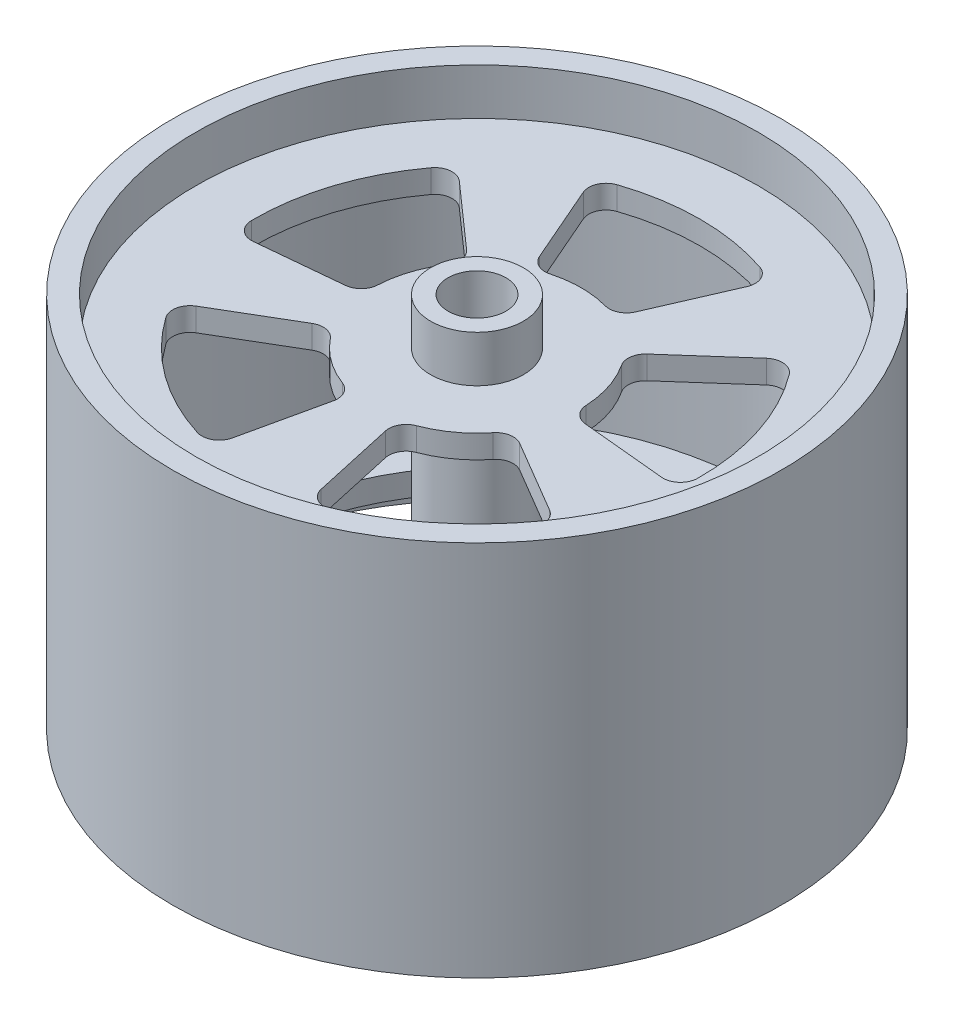
from build123d import *

# Parameters (mm, degrees)
SKETCH1_R           = 52.5
SKETCH1_R_2         = 48.5
BOSS_EXTRUDE1_DEPTH = 65
SKETCH2_R           = 5
BOSS_EXTRUDE2_DEPTH = 65
BOSS_EXTRUDE3_START = -8
SKETCH2_3_R         = 48.5
SKETCH2_3_R_2       = 8
BOSS_EXTRUDE3_DEPTH = 4
BOSS_EXTRUDE4_START = -53
SKETCH2_4_R         = 48.5
SKETCH2_4_R_2       = 8
BOSS_EXTRUDE4_DEPTH = 4


with BuildPart() as part:
    # Sketch1 → Boss-Extrude1 (new body)
    with BuildSketch(Plane(origin=(0, 0, 0), x_dir=(1, 0, 0), z_dir=(0, 1, 0))):
        Circle(SKETCH1_R)
        Circle(SKETCH1_R_2, mode=Mode.SUBTRACT)
    extrude(amount=BOSS_EXTRUDE1_DEPTH)



with BuildPart() as body_2:
    # Sketch2 → Boss-Extrude2 (new body)
    with BuildSketch(Plane.XZ):
        with BuildLine():
            ThreePointArc((8, 0), (7.901506725, 1.25147572), (7.60845213, 2.472135955))
            ThreePointArc((7.60845213, 2.472135955), (4.702282018, 6.472135955), (0, 8))
            ThreePointArc((0, 8), (-5.656854249, -5.656854249), (8, 0))
        make_face()
        Circle(SKETCH2_R, mode=Mode.SUBTRACT)
    extrude(amount=-BOSS_EXTRUDE2_DEPTH)


with BuildPart() as part_1:
    add(part.part)

    add(body_2.part)  # Boss-Extrude3 merges body 2
    # Sketch2_3 → Boss-Extrude3 (add)
    with BuildSketch(Plane.XZ.offset(BOSS_EXTRUDE3_START)):
        Circle(SKETCH2_3_R)
        Circle(SKETCH2_3_R_2, mode=Mode.SUBTRACT)
        with BuildLine():
            Line((4.498612897, 20.291931451), (7.656121129, 34.53453068))
            ThreePointArc((7.656121129, 34.53453068), (9.081556968, 36.48129187), (11.479516965, 36.748750866))
            ThreePointArc((11.479516965, 36.748750866), (22.629732213, 31.147154283), (31.402773148, 22.273657954))
            ThreePointArc((31.402773148, 22.273657954), (31.889414918, 19.910413097), (30.4784189, 17.953160762))
            Line((30.4784189, 17.953160762), (17.908625798, 10.548986777))
            ThreePointArc((17.908625798, 10.548986777), (15.84479345, 10.183097432), (14.045152036, 11.257606507))
            ThreePointArc((14.045152036, 11.257606507), (10.580134541, 14.562305899), (6.366429359, 16.836525093))
            ThreePointArc((6.366429359, 16.836525093), (4.78839072, 18.216044222), (4.498612897, 20.291931451))
        make_face(mode=Mode.SUBTRACT)
        with BuildLine():
            ThreePointArc((-31.402773148, 22.273657954), (-22.629732213, 31.147154283), (-11.479516965, 36.748750866))
            ThreePointArc((-11.479516965, 36.748750866), (-9.081556968, 36.48129187), (-7.656121129, 34.53453068))
            Line((-7.656121129, 34.53453068), (-4.498612897, 20.291931451))
            ThreePointArc((-4.498612897, 20.291931451), (-4.78839072, 18.216044222), (-6.366429359, 16.836525093))
            ThreePointArc((-6.366429359, 16.836525093), (-10.580134541, 14.562305899), (-14.045152036, 11.257606507))
            ThreePointArc((-14.045152036, 11.257606507), (-15.84479345, 10.183097432), (-17.908625798, 10.548986777))
            Line((-17.908625798, 10.548986777), (-30.4784189, 17.953160762))
            ThreePointArc((-30.4784189, 17.953160762), (-31.889414918, 19.910413097), (-31.402773148, 22.273657954))
        make_face(mode=Mode.SUBTRACT)
        with BuildLine():
            Line((8.287843762, -19.060735709), (14.104955724, -32.439177302))
            ThreePointArc((14.104955724, -32.439177302), (14.096031424, -34.851990353), (12.313249487, -36.477854749))
            ThreePointArc((12.313249487, -36.477854749), (0, -38.5), (-12.313249487, -36.477854749))
            ThreePointArc((-12.313249487, -36.477854749), (-14.096031424, -34.851990353), (-14.104955724, -32.439177302))
            Line((-14.104955724, -32.439177302), (-8.287843762, -19.060735709))
            ThreePointArc((-8.287843762, -19.060735709), (-6.83323268, -17.551634794), (-4.745711605, -17.363128214))
            ThreePointArc((-4.745711605, -17.363128214), (0, -18), (4.745711605, -17.363128214))
            ThreePointArc((4.745711605, -17.363128214), (6.83323268, -17.551634794), (8.287843762, -19.060735709))
        make_face(mode=Mode.SUBTRACT)
        with BuildLine():
            Line((-15.566752332, -13.772299075), (-26.492819932, -23.438867123))
            ThreePointArc((-26.492819932, -23.438867123), (-28.790299268, -24.175979847), (-30.887498112, -22.982873197))
            ThreePointArc((-30.887498112, -22.982873197), (-36.615675877, -11.897154283), (-38.497504807, 0.438319126))
            ThreePointArc((-38.497504807, 0.438319126), (-37.502125795, 2.636265233), (-35.21016198, 3.390352984))
            Line((-35.21016198, 3.390352984), (-20.688921471, 1.992116557))
            ThreePointArc((-20.688921471, 1.992116557), (-18.804181667, 1.075037038), (-17.979821767, -0.852061747))
            ThreePointArc((-17.979821767, -0.852061747), (-17.119017293, -5.562305899), (-15.046810695, -9.87894164))
            ThreePointArc((-15.046810695, -9.87894164), (-14.581011618, -11.922543898), (-15.566752332, -13.772299075))
        make_face(mode=Mode.SUBTRACT)
        with BuildLine():
            Line((20.688921471, 1.992116557), (35.21016198, 3.390352984))
            ThreePointArc((35.21016198, 3.390352984), (37.502125795, 2.636265233), (38.497504807, 0.438319126))
            ThreePointArc((38.497504807, 0.438319126), (36.615675877, -11.897154283), (30.887498112, -22.982873197))
            ThreePointArc((30.887498112, -22.982873197), (28.790299268, -24.175979847), (26.492819932, -23.438867123))
            Line((26.492819932, -23.438867123), (15.566752332, -13.772299075))
            ThreePointArc((15.566752332, -13.772299075), (14.581011618, -11.922543898), (15.046810695, -9.87894164))
            ThreePointArc((15.046810695, -9.87894164), (17.119017293, -5.562305899), (17.979821767, -0.852061747))
            ThreePointArc((17.979821767, -0.852061747), (18.804181667, 1.075037038), (20.688921471, 1.992116557))
        make_face(mode=Mode.SUBTRACT)
    extrude(amount=-BOSS_EXTRUDE3_DEPTH)

    # Sketch2_4 → Boss-Extrude4 (add)
    with BuildSketch(Plane.XZ.offset(BOSS_EXTRUDE4_START)):
        Circle(SKETCH2_4_R)
        Circle(SKETCH2_4_R_2, mode=Mode.SUBTRACT)
        with BuildLine():
            Line((4.498612897, 20.291931451), (7.656121129, 34.53453068))
            ThreePointArc((7.656121129, 34.53453068), (9.081556968, 36.48129187), (11.479516965, 36.748750866))
            ThreePointArc((11.479516965, 36.748750866), (22.629732213, 31.147154283), (31.402773148, 22.273657954))
            ThreePointArc((31.402773148, 22.273657954), (31.889414918, 19.910413097), (30.4784189, 17.953160762))
            Line((30.4784189, 17.953160762), (17.908625798, 10.548986777))
            ThreePointArc((17.908625798, 10.548986777), (15.84479345, 10.183097432), (14.045152036, 11.257606507))
            ThreePointArc((14.045152036, 11.257606507), (10.580134541, 14.562305899), (6.366429359, 16.836525093))
            ThreePointArc((6.366429359, 16.836525093), (4.78839072, 18.216044222), (4.498612897, 20.291931451))
        make_face(mode=Mode.SUBTRACT)
        with BuildLine():
            ThreePointArc((-31.402773148, 22.273657954), (-22.629732213, 31.147154283), (-11.479516965, 36.748750866))
            ThreePointArc((-11.479516965, 36.748750866), (-9.081556968, 36.48129187), (-7.656121129, 34.53453068))
            Line((-7.656121129, 34.53453068), (-4.498612897, 20.291931451))
            ThreePointArc((-4.498612897, 20.291931451), (-4.78839072, 18.216044222), (-6.366429359, 16.836525093))
            ThreePointArc((-6.366429359, 16.836525093), (-10.580134541, 14.562305899), (-14.045152036, 11.257606507))
            ThreePointArc((-14.045152036, 11.257606507), (-15.84479345, 10.183097432), (-17.908625798, 10.548986777))
            Line((-17.908625798, 10.548986777), (-30.4784189, 17.953160762))
            ThreePointArc((-30.4784189, 17.953160762), (-31.889414918, 19.910413097), (-31.402773148, 22.273657954))
        make_face(mode=Mode.SUBTRACT)
        with BuildLine():
            Line((8.287843762, -19.060735709), (14.104955724, -32.439177302))
            ThreePointArc((14.104955724, -32.439177302), (14.096031424, -34.851990353), (12.313249487, -36.477854749))
            ThreePointArc((12.313249487, -36.477854749), (0, -38.5), (-12.313249487, -36.477854749))
            ThreePointArc((-12.313249487, -36.477854749), (-14.096031424, -34.851990353), (-14.104955724, -32.439177302))
            Line((-14.104955724, -32.439177302), (-8.287843762, -19.060735709))
            ThreePointArc((-8.287843762, -19.060735709), (-6.83323268, -17.551634794), (-4.745711605, -17.363128214))
            ThreePointArc((-4.745711605, -17.363128214), (0, -18), (4.745711605, -17.363128214))
            ThreePointArc((4.745711605, -17.363128214), (6.83323268, -17.551634794), (8.287843762, -19.060735709))
        make_face(mode=Mode.SUBTRACT)
        with BuildLine():
            Line((-15.566752332, -13.772299075), (-26.492819932, -23.438867123))
            ThreePointArc((-26.492819932, -23.438867123), (-28.790299268, -24.175979847), (-30.887498112, -22.982873197))
            ThreePointArc((-30.887498112, -22.982873197), (-36.615675877, -11.897154283), (-38.497504807, 0.438319126))
            ThreePointArc((-38.497504807, 0.438319126), (-37.502125795, 2.636265233), (-35.21016198, 3.390352984))
            Line((-35.21016198, 3.390352984), (-20.688921471, 1.992116557))
            ThreePointArc((-20.688921471, 1.992116557), (-18.804181667, 1.075037038), (-17.979821767, -0.852061747))
            ThreePointArc((-17.979821767, -0.852061747), (-17.119017293, -5.562305899), (-15.046810695, -9.87894164))
            ThreePointArc((-15.046810695, -9.87894164), (-14.581011618, -11.922543898), (-15.566752332, -13.772299075))
        make_face(mode=Mode.SUBTRACT)
        with BuildLine():
            Line((20.688921471, 1.992116557), (35.21016198, 3.390352984))
            ThreePointArc((35.21016198, 3.390352984), (37.502125795, 2.636265233), (38.497504807, 0.438319126))
            ThreePointArc((38.497504807, 0.438319126), (36.615675877, -11.897154283), (30.887498112, -22.982873197))
            ThreePointArc((30.887498112, -22.982873197), (28.790299268, -24.175979847), (26.492819932, -23.438867123))
            Line((26.492819932, -23.438867123), (15.566752332, -13.772299075))
            ThreePointArc((15.566752332, -13.772299075), (14.581011618, -11.922543898), (15.046810695, -9.87894164))
            ThreePointArc((15.046810695, -9.87894164), (17.119017293, -5.562305899), (17.979821767, -0.852061747))
            ThreePointArc((17.979821767, -0.852061747), (18.804181667, 1.075037038), (20.688921471, 1.992116557))
        make_face(mode=Mode.SUBTRACT)
    extrude(amount=-BOSS_EXTRUDE4_DEPTH)


solid = part_1.part
